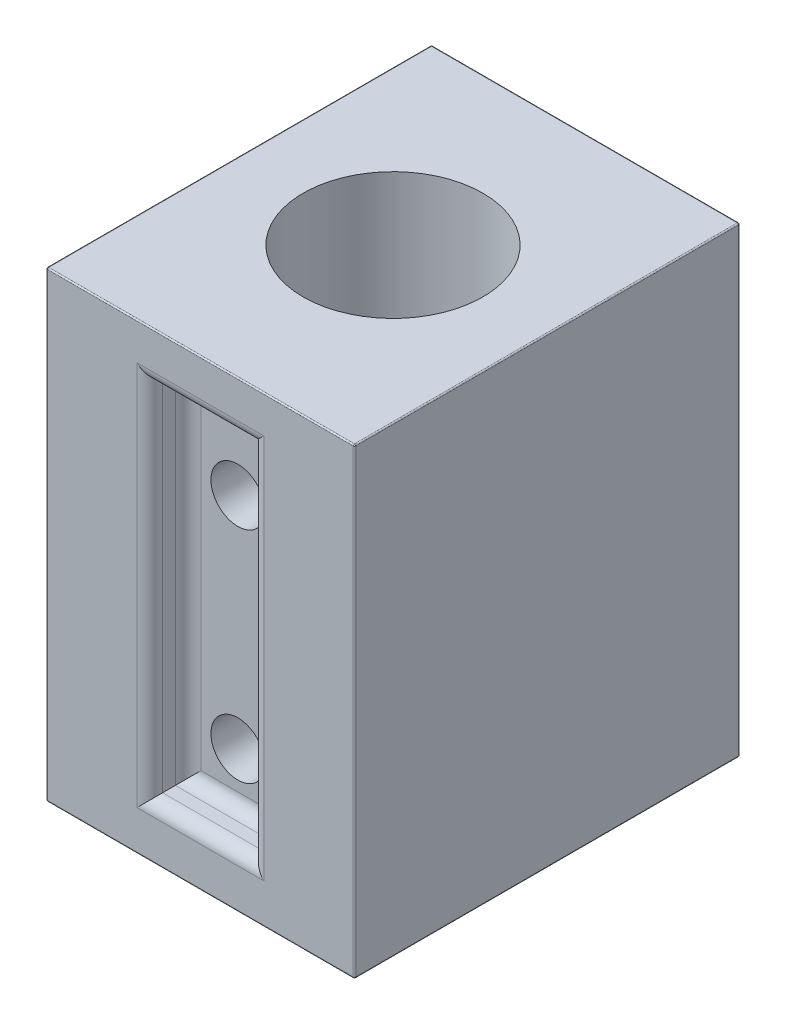
from build123d import *

# Parameters (mm, degrees)
SKETCH2_W           = 12
SKETCH2_H           = 18
BOSS_EXTRUDE1_DEPTH = 15
SKETCH5_R           = 3.5
CUT_EXTRUDE2_DEPTH  = 18
SKETCH8_W           = 3.937037176
SKETCH8_H           = 14
CUT_EXTRUDE3_DEPTH  = 1.492750999
FILLET3_R           = 0.05
SKETCH10_R          = 1.05
CUT_EXTRUDE6_DEPTH  = 3
FILLET9_R           = 0.5
FILLET10_R          = 0.5


with BuildPart() as part:
    # Sketch2 → Boss-Extrude1 (new body)
    with BuildSketch(Plane.XY):
        Rectangle(SKETCH2_W, SKETCH2_H)
    extrude(amount=BOSS_EXTRUDE1_DEPTH)

    # Sketch5 → Cut-Extrude2 (cut)
    with BuildSketch(Plane(origin=(0, -9, 0), x_dir=(-1, 0, 0), z_dir=(0, -1, 0))):
        with Locations((0, -7.5)):
            Circle(SKETCH5_R)
    extrude(amount=-CUT_EXTRUDE2_DEPTH, mode=Mode.SUBTRACT)

    # Sketch8 → Cut-Extrude3 (cut)
    with BuildSketch(Plane.XY.offset(15)):
        with Locations((0, 0.05)):
            Rectangle(SKETCH8_W, SKETCH8_H)
    extrude(amount=-CUT_EXTRUDE3_DEPTH, mode=Mode.SUBTRACT)

    # Fillet3
    fillet3_edges = [part.edges().sort_by_distance(p)[0] for p in [
        (-6, 0, 15),
        (0, -9, 15),
        (6, 0, 15),
        (0, -9, 0),
        (-6, 0, 0),
        (0, 9, 0),
        (6, 0, 0),
        (0, 9, 15),
        (6, -9, 7.5),
        (-6, -9, 7.5),
        (-6, 9, 7.5),
        (6, 9, 7.5),
    ]]
    fillet(fillet3_edges, radius=FILLET3_R)

    # Sketch10 → Cut-Extrude6 (cut)
    with BuildSketch(Plane.XY.offset(13.507249001)):
        with Locations((-0.031481412, 3.55)):
            Circle(SKETCH10_R)
        with Locations((-0.031481412, -5)):
            Circle(SKETCH10_R)
    extrude(amount=-CUT_EXTRUDE6_DEPTH, mode=Mode.SUBTRACT)

    # Fillet9
    fillet9_edges = [part.edges().sort_by_distance(p)[0] for p in [
        (-1.968518588, 0.05, 15),
        (0, -6.95, 15),
        (1.968518588, 0.05, 15),
        (0, 7.05, 15),
    ]]
    fillet(fillet9_edges, radius=FILLET9_R)

    # Fillet10
    fillet10_edges = [part.edges().sort_by_distance(p)[0] for p in [
        (-1.968518588, 0.05, 13.507249001),
        (0, 7.05, 13.507249001),
        (1.968518588, 0.05, 13.507249001),
        (0, -6.95, 13.507249001),
    ]]
    fillet(fillet10_edges, radius=FILLET10_R)


solid = part.part
